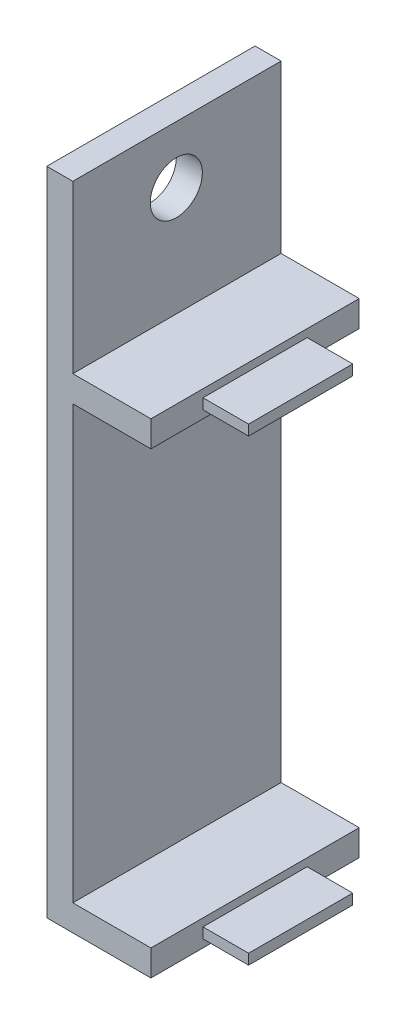
from build123d import *

# Parameters (mm, degrees)
BOSS_EXTRUDE1_DEPTH = 10.16
SKETCH6_W           = 10.16
SKETCH6_H           = 1.27
BOSS_EXTRUDE3_DEPTH = 3.81
SKETCH23_W          = 5.08
SKETCH23_H          = 0.508
BOSS_EXTRUDE4_DEPTH = 2.2225
SKETCH25_W          = 5.08
SKETCH25_H          = 0.508
BOSS_EXTRUDE5_DEPTH = 2.2225
SKETCH26_R          = 1.27
CUT_EXTRUDE1_DEPTH  = 2.2225


with BuildPart() as part:
    # Sketch1 → Boss-Extrude1 (new body)
    with BuildSketch(Plane.XY):
        Polygon((-22.483233333, 11.63955), (-22.483233333, -18.84045), (-18.673233333, -18.84045), (-18.673233333, -20.11045), (-23.753233333, -20.11045), (-23.753233333, 11.63955), align=None)
    extrude(amount=BOSS_EXTRUDE1_DEPTH)

    # Sketch6 → Boss-Extrude3 (add)
    with BuildSketch(Plane(origin=(-22.483233333, 0, 0), x_dir=(0, 0, -1), z_dir=(1, 0, 0))):
        with Locations((-5.08, 2.87655)):
            Rectangle(SKETCH6_W, SKETCH6_H)
    extrude(amount=BOSS_EXTRUDE3_DEPTH)

    # Sketch23 → Boss-Extrude4 (add)
    with BuildSketch(Plane(origin=(-18.673233333, 0, 0), x_dir=(0, 0, -1), z_dir=(1, 0, 0))):
        with Locations((-5.08, 2.87655)):
            Rectangle(SKETCH23_W, SKETCH23_H)
    extrude(amount=BOSS_EXTRUDE4_DEPTH)

    # Sketch25 → Boss-Extrude5 (add)
    with BuildSketch(Plane(origin=(-18.673233333, 0, 0), x_dir=(0, 0, -1), z_dir=(1, 0, 0))):
        with Locations((-5.08, -19.47545)):
            Rectangle(SKETCH25_W, SKETCH25_H)
    extrude(amount=BOSS_EXTRUDE5_DEPTH)

    # Sketch26 → Cut-Extrude1 (cut)
    with BuildSketch(Plane(origin=(-22.483233333, 0, 0), x_dir=(0, 0, -1), z_dir=(1, 0, 0))):
        with Locations((-5.111682079, 8.84555)):
            Circle(SKETCH26_R)
    extrude(amount=-CUT_EXTRUDE1_DEPTH, mode=Mode.SUBTRACT)


solid = part.part
